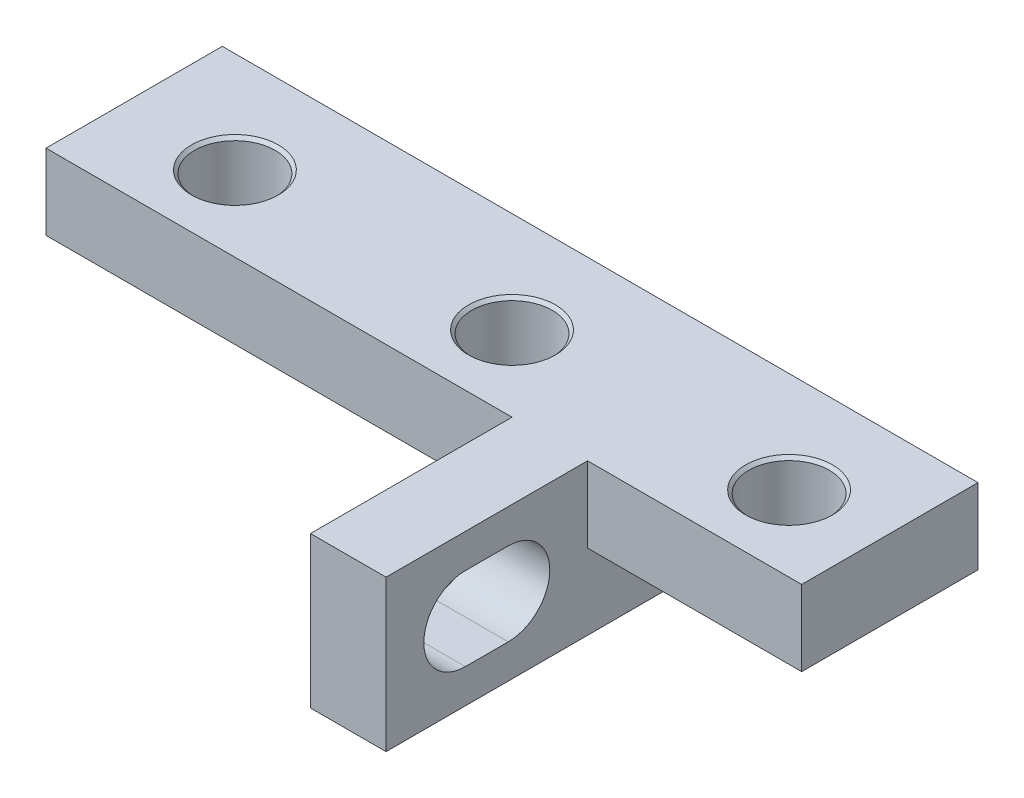
from build123d import *

# Parameters (mm, degrees)
EXTRUDE_1_DEPTH            = 15
SKETCH_2_W                 = 3
SKETCH_2_H                 = 19
SKETCH_2_W_2               = 10
SKETCH_2_H_2               = 3
CUT_EXTRUDE_1_DEPTH        = 16
SKETCH_3_W                 = 18.5
SKETCH_3_H                 = 3
SKETCH_3_W_2               = 8.5
CUT_EXTRUDE_3_DEPTH        = 8
HOLE_WIZARD_M31_AT_2_COUNT = 2
HOLE_WIZARD_M31_AT_2_PITCH = 22
HOLE_WIZARD_M31_AT_3_COUNT = 2
HOLE_WIZARD_M31_AT_3_PITCH = 11
CUT_EXTRUDE_4_REACH        = 23.5


with BuildPart() as part:
    # Эскиз1 → Бобышка-Вытянуть1 (new body)
    with BuildSketch(Plane.XY):
        Polygon((-1.5, 0), (-1.5, 22), (-20, 22), (-20, 25), (20, 25), (20, 22), (1.5, 22), (1.5, 0), align=None)
    extrude(amount=EXTRUDE_1_DEPTH)

    # Эскиз2 → Вырез-Вытянуть1 (cut, through all)
    with BuildSketch(Plane.XY.offset(15)):
        with Locations((0, 9.5)):
            Rectangle(SKETCH_2_W, SKETCH_2_H)
        with Locations((15, 23.5)):
            Rectangle(SKETCH_2_W_2, SKETCH_2_H_2)
    extrude(amount=-CUT_EXTRUDE_1_DEPTH, mode=Mode.SUBTRACT)

    # Эскиз3 → Вырез-Вытянуть3 (cut)
    with BuildSketch(Plane.XY.offset(15)):
        with Locations((-10.75, 23.5)):
            Rectangle(SKETCH_3_W, SKETCH_3_H)
        with Locations((5.75, 23.5)):
            Rectangle(SKETCH_3_W_2, SKETCH_3_H)
    extrude(amount=-CUT_EXTRUDE_3_DEPTH, mode=Mode.SUBTRACT)

    # Эскиз4 → Отверстие с зазором M31 (revolve, cut)
    with BuildSketch(Plane(origin=(-15.5, 22, 4), x_dir=(0, 0, -1), z_dir=(1, 0, 0))):
        Polygon((0, 0), (0, 3), (1.725, 3), (1.6, 2.875), (1.6, 0.125), (1.725, 0), align=None)
    hole_wizard_m31 = revolve(axis=Axis((-15.5, 15.65, 4), (0, 1, 0)), mode=Mode.SUBTRACT)

    # Отверстие с зазором M31 at 2: Отверстие с зазором M31 ×2
    with Locations(*[(i * HOLE_WIZARD_M31_AT_2_PITCH, 0, 0) for i in range(1, HOLE_WIZARD_M31_AT_2_COUNT)]):
        add(hole_wizard_m31, mode=Mode.SUBTRACT)

    # Отверстие с зазором M31 at 3: Отверстие с зазором M31 ×2
    with Locations(*[(i * HOLE_WIZARD_M31_AT_3_PITCH, 0, 0) for i in range(1, HOLE_WIZARD_M31_AT_3_COUNT)]):
        add(hole_wizard_m31, mode=Mode.SUBTRACT)

    # Эскиз6 → Вырез-Вытянуть4 (cut, up to next)
    with BuildSketch(Plane(origin=(1.5, 0, 0), x_dir=(0, 0, -1), z_dir=(1, 0, 0)), mode=Mode.PRIVATE) as cut_extrude_4_sk1:
        with BuildLine():
            Line((-11.85, 23.65), (-10.15, 23.65))
            ThreePointArc((-10.15, 23.65), (-8.5, 22), (-10.15, 20.35))
            Line((-10.15, 20.35), (-11.85, 20.35))
            ThreePointArc((-11.85, 20.35), (-13.5, 22), (-11.85, 23.65))
        make_face()
    cut_extrude_4_tool1 = extrude(cut_extrude_4_sk1.sketch, amount=-CUT_EXTRUDE_4_REACH, mode=Mode.PRIVATE) & part.part
    add(cut_extrude_4_tool1.solids().sort_by_distance((1.5, 22, 11))[0], mode=Mode.SUBTRACT)


solid = part.part
